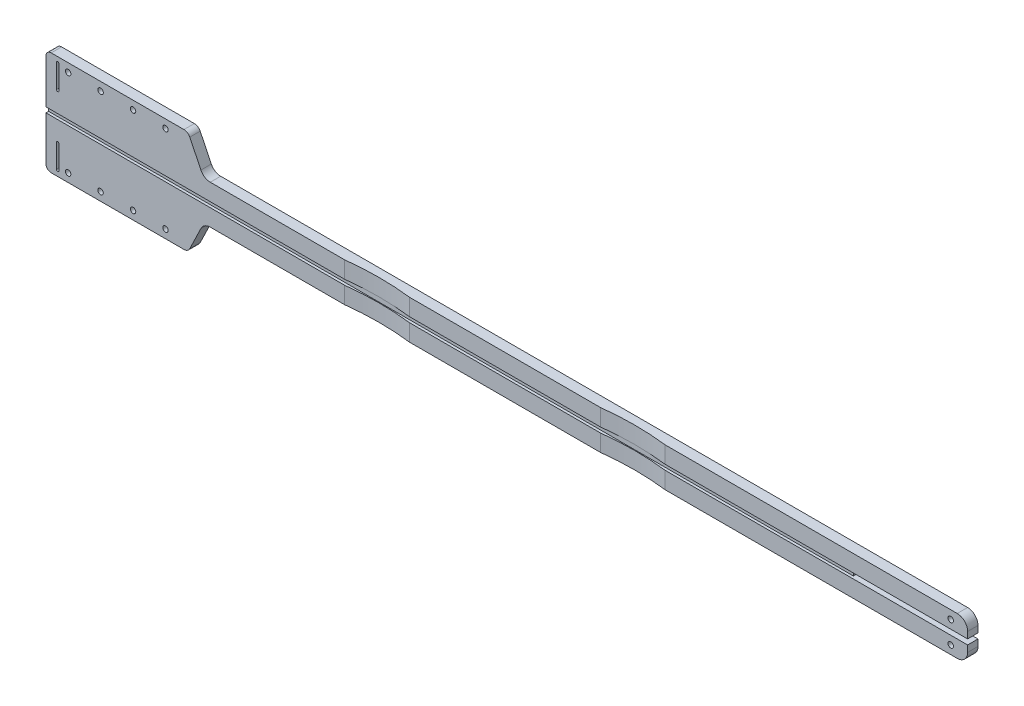
from build123d import *

# Parameters (mm, degrees)
MODEL_R                 = 2.1
BOSS_EXTRU_1_DEPTH      = 8
ESQUISSE2_W             = 619.951628201
ESQUISSE2_H             = 4
ENL_V_MAT_EXTRU_1_DEPTH = 2
CHANFREIN1_SIZE         = 1
ENL_V_MAT_EXTRU_2_DEPTH = 55.986789313


with BuildPart() as part:
    # Model → Boss.-Extru.1 (new body)
    with BuildSketch(Plane.XY):
        with BuildLine():
            Line((5.807601336, 84.65), (5.807601336, 156.65))
            ThreePointArc((5.807601336, 156.65), (6.979174211, 159.478427125), (9.807601336, 160.65))
            Line((9.807601336, 160.65), (112.089987365, 160.65))
            ThreePointArc((112.089987365, 160.65), (114.746116476, 159.886151336), (116.590693318, 157.827991258))
            Line((116.590693318, 157.827991258), (125.144495245, 140.1520033))
            ThreePointArc((125.144495245, 140.1520033), (128.095818192, 136.858947175), (132.34562477, 135.636789313))
            Line((132.34562477, 135.636789313), (707.759229537, 135.636789313))
            ThreePointArc((707.759229537, 135.636789313), (713.416083787, 133.293643563), (715.759229537, 127.636789313))
            Line((715.759229537, 127.636789313), (715.759229537, 122.65))
            Line((715.759229537, 122.65), (625.759229537, 122.65))
            Line((625.759229537, 122.65), (625.759229537, 118.65))
            Line((625.759229537, 118.65), (715.759229537, 118.65))
            Line((715.759229537, 118.65), (715.759229537, 113.663210687))
            ThreePointArc((715.759229537, 113.663210687), (713.416083787, 108.006356437), (707.759229537, 105.663210687))
            Line((707.759229537, 105.663210687), (132.34562477, 105.663210687))
            ThreePointArc((132.34562477, 105.663210687), (128.095818192, 104.441052825), (125.144495245, 101.1479967))
            Line((125.144495245, 101.1479967), (116.590693318, 83.472008742))
            ThreePointArc((116.590693318, 83.472008742), (114.746116476, 81.413848664), (112.089987365, 80.65))
            Line((112.089987365, 80.65), (9.807601336, 80.65))
            ThreePointArc((9.807601336, 80.65), (6.979174211, 81.821572875), (5.807601336, 84.65))
        make_face()
        with Locations((702.759229537, 129.143394657)):
            Circle(MODEL_R, mode=Mode.SUBTRACT)
        with Locations((702.759229537, 112.156605343)):
            Circle(MODEL_R, mode=Mode.SUBTRACT)
        with Locations((47.853374331, 154.15)):
            Circle(MODEL_R, mode=Mode.SUBTRACT)
        with Locations((97.853374331, 154.15)):
            Circle(MODEL_R, mode=Mode.SUBTRACT)
        with Locations((22.853374331, 154.15)):
            Circle(MODEL_R, mode=Mode.SUBTRACT)
        with Locations((72.853374331, 154.15)):
            Circle(MODEL_R, mode=Mode.SUBTRACT)
        with Locations((47.853374331, 87.15)):
            Circle(MODEL_R, mode=Mode.SUBTRACT)
        with Locations((97.853374331, 87.15)):
            Circle(MODEL_R, mode=Mode.SUBTRACT)
        with Locations((22.853374331, 87.15)):
            Circle(MODEL_R, mode=Mode.SUBTRACT)
        with Locations((72.853374331, 87.15)):
            Circle(MODEL_R, mode=Mode.SUBTRACT)
        with BuildLine():
            Line((15.807601336, 84.988017314), (15.807601336, 102.988017314))
            ThreePointArc((15.807601336, 102.988017314), (14.807601336, 103.988017314), (13.807601336, 102.988017314))
            Line((13.807601336, 102.988017314), (13.807601336, 84.988017314))
            ThreePointArc((13.807601336, 84.988017314), (14.807601336, 83.988017314), (15.807601336, 84.988017314))
        make_face(mode=Mode.SUBTRACT)
        with BuildLine():
            Line((15.807601336, 156.311982686), (15.807601336, 138.311982686))
            ThreePointArc((15.807601336, 138.311982686), (14.807601336, 137.311982686), (13.807601336, 138.311982686))
            Line((13.807601336, 138.311982686), (13.807601336, 156.311982686))
            ThreePointArc((13.807601336, 156.311982686), (14.807601336, 157.311982686), (15.807601336, 156.311982686))
        make_face(mode=Mode.SUBTRACT)
    extrude(amount=BOSS_EXTRU_1_DEPTH)

    # Esquisse2 → Enlèv. mat.-Extru.1 (cut)
    with BuildSketch(Plane.XY.offset(8)):
        with Locations((315.783415436, 120.65)):
            Rectangle(ESQUISSE2_W, ESQUISSE2_H)
    extrude(amount=-ENL_V_MAT_EXTRU_1_DEPTH, mode=Mode.SUBTRACT)

    # Chanfrein1
    chanfrein1_edges = [part.edges().sort_by_distance(p)[0] for p in [
        (14.807601336, 103.988017314, 0),
        (13.807601336, 93.988017314, 0),
        (14.807601336, 83.988017314, 0),
        (15.807601336, 93.988017314, 0),
        (700.659229537, 129.143394657, 0),
        (700.659229537, 112.156605343, 0),
        (45.753374331, 154.15, 0),
        (95.753374331, 154.15, 0),
        (20.753374331, 154.15, 0),
        (70.753374331, 154.15, 0),
        (45.753374331, 87.15, 0),
        (95.753374331, 87.15, 0),
        (20.753374331, 87.15, 0),
        (70.753374331, 87.15, 0),
        (14.807601336, 157.311982686, 0),
        (13.807601336, 147.311982686, 0),
        (14.807601336, 137.311982686, 0),
        (15.807601336, 147.311982686, 0),
    ]]
    chamfer(chanfrein1_edges, length=CHANFREIN1_SIZE)

    # Esquisse3 → Enlèv. mat.-Extru.2 (cut, through all)
    with BuildSketch(Plane.XZ.offset(-105.663210687)):
        with BuildLine():
            Line((235.807601336, 8), (285.807601336, 8))
            ThreePointArc((285.807601336, 8), (260.807601336, 6.5), (235.807601336, 8))
        make_face()
        with BuildLine():
            Line((432.807601336, 8), (482.807601336, 8))
            ThreePointArc((482.807601336, 8), (457.807601336, 6.5), (432.807601336, 8))
        make_face()
    extrude(amount=-ENL_V_MAT_EXTRU_2_DEPTH, mode=Mode.SUBTRACT)


solid = part.part
